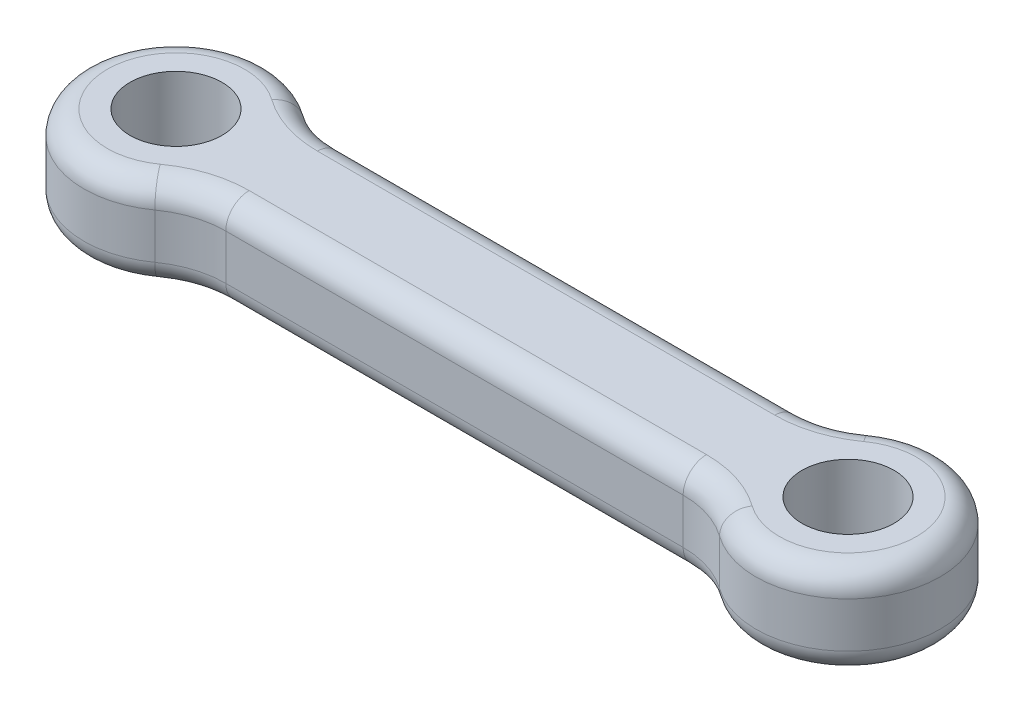
from build123d import *

# Parameters (mm, degrees)
SKETCH1_R           = 5
BOSS_EXTRUDE1_DEPTH = 10
FILLET1_R           = 2.54


with BuildPart() as part:
    # Sketch1 → Boss-Extrude1 (new body)
    with BuildSketch(Plane(origin=(0, 0, 0), x_dir=(1, 0, 0), z_dir=(0, 1, 0))):
        with BuildLine():
            Line((-6.590776184, -6.25), (43.090776184, -6.25))
            ThreePointArc((43.090776184, -6.25), (46.152638362, -6.730283618), (48.920388092, -8.125))
            ThreePointArc((48.920388092, -8.125), (64.75, 0), (48.920388092, 8.125))
            ThreePointArc((48.920388092, 8.125), (46.152638362, 6.730283618), (43.090776184, 6.25))
            Line((43.090776184, 6.25), (-6.590776184, 6.25))
            ThreePointArc((-6.590776184, 6.25), (-9.652638362, 6.730283618), (-12.420388092, 8.125))
            ThreePointArc((-12.420388092, 8.125), (-28.25, 0), (-12.420388092, -8.125))
            ThreePointArc((-12.420388092, -8.125), (-9.652638362, -6.730283618), (-6.590776184, -6.25))
        make_face()
        with Locations((-18.25, 0)):
            Circle(SKETCH1_R, mode=Mode.SUBTRACT)
        with Locations((54.75, 0)):
            Circle(SKETCH1_R, mode=Mode.SUBTRACT)
    extrude(amount=BOSS_EXTRUDE1_DEPTH)

    # Fillet1
    fillet1_edges = [part.edges().sort_by_distance(p)[0] for p in [
        (-9.652638362, 10, 6.730283618),
        (-28.25, 0, 0),
        (-9.652638362, 0, -6.730283618),
        (18.25, 10, 6.25),
        (46.152638362, 10, 6.730283618),
        (64.75, 10, 0),
        (46.152638362, 10, -6.730283618),
        (18.25, 10, -6.25),
        (-9.652638362, 10, -6.730283618),
        (-28.25, 10, 0),
        (18.25, 0, -6.25),
        (46.152638362, 0, -6.730283618),
        (64.75, 0, 0),
        (46.152638362, 0, 6.730283618),
        (18.25, 0, 6.25),
        (-9.652638362, 0, 6.730283618),
    ]]
    fillet(fillet1_edges, radius=FILLET1_R)


solid = part.part
